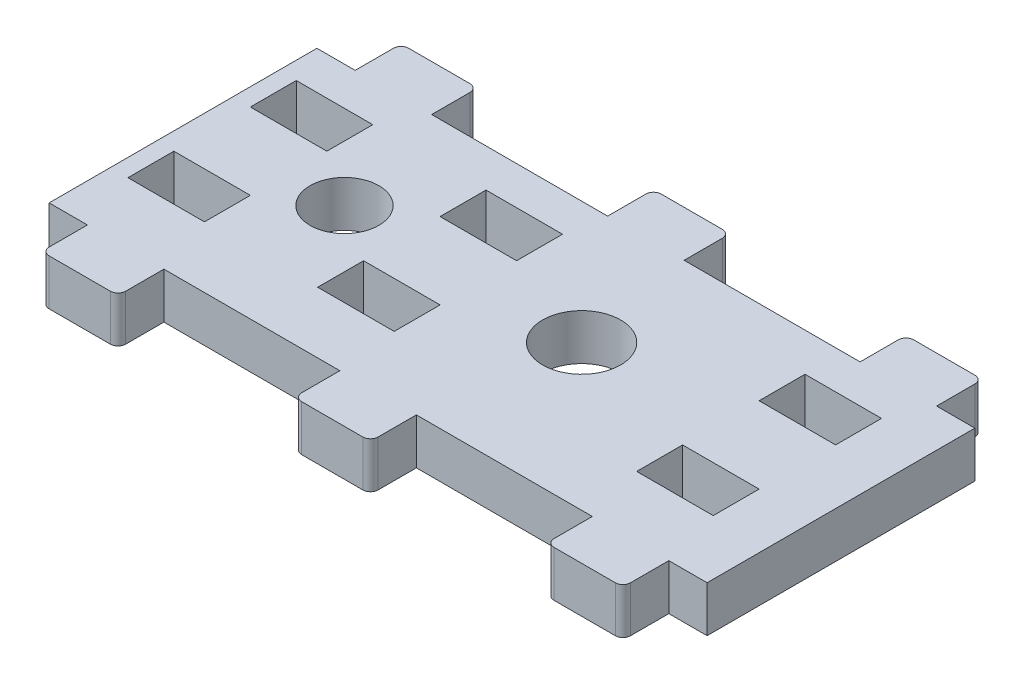
from build123d import *

# Parameters (mm, degrees)
SKETCH1_W               = 86
SKETCH1_H               = 35
BOSS_EXTRUDE1_DEPTH     = 6
SKETCH2_R               = 5.1
SKETCH2_R_2             = 4.5
CUT_EXTRUDE1_DEPTH      = 6
SKETCH234_W             = 10
SKETCH234_H             = 6
BOSS_EXTRUDE234_DEPTH   = 6
FILLET134_R             = 1
SKETCH2341_W            = 10
SKETCH2341_H            = 6
BOSS_EXTRUDE2341_DEPTH  = 6
FILLET1341_R            = 1
SKETCH2342_W            = 10
SKETCH2342_H            = 6
BOSS_EXTRUDE2342_DEPTH  = 6
FILLET1342_R            = 1
FILLET134_OF_MIRROR1_R  = 1
FILLET1341_OF_MIRROR1_R = 1
FILLET1342_OF_MIRROR1_R = 1
SKETCH6_W               = 10
SKETCH6_H               = 6
CUT_EXTRUDE11_DEPTH     = 4
SKETCH61_W              = 10
SKETCH61_H              = 6
CUT_EXTRUDE12_DEPTH     = 4
SKETCH62_W              = 10
SKETCH62_H              = 6
CUT_EXTRUDE13_DEPTH     = 4


with BuildPart() as part:
    # Sketch1 → Boss-Extrude1 (new body)
    with BuildSketch(Plane(origin=(0, 0, 0), x_dir=(1, 0, 0), z_dir=(0, 1, 0))):
        with Locations((43, 17.5)):
            Rectangle(SKETCH1_W, SKETCH1_H)
    extrude(amount=BOSS_EXTRUDE1_DEPTH)

    # Sketch2 → Cut-Extrude1 (cut)
    with BuildSketch(Plane(origin=(0, 6, 0), x_dir=(1, 0, 0), z_dir=(0, 1, 0))):
        with Locations((50.6, 19)):
            Circle(SKETCH2_R)
        with Locations((19.6, 19)):
            Circle(SKETCH2_R_2)
    extrude(amount=-CUT_EXTRUDE1_DEPTH, mode=Mode.SUBTRACT)

    # Sketch234 → Boss-Extrude234 (add)
    with BuildSketch(Plane(origin=(9.232221392, 0, 0), x_dir=(1, 0, 0), z_dir=(0, 0, 1))):
        with Locations((0.767778608, 3)):
            Rectangle(SKETCH234_W, SKETCH234_H)
    boss_extrude234 = extrude(amount=BOSS_EXTRUDE234_DEPTH)

    # Fillet134
    fillet134_edges = [part.edges().sort_by_distance(p)[0] for p in [
        (5, 3, 6),
        (15, 3, 6),
    ]]
    fillet(fillet134_edges, radius=FILLET134_R)

    # Sketch2341 → Boss-Extrude2341 (add)
    with BuildSketch(Plane(origin=(42.232221392, 0, 0), x_dir=(1, 0, 0), z_dir=(0, 0, 1))):
        with Locations((0.767778608, 3)):
            Rectangle(SKETCH2341_W, SKETCH2341_H)
    boss_extrude2341 = extrude(amount=BOSS_EXTRUDE2341_DEPTH)

    # Fillet1341
    fillet1341_edges = [part.edges().sort_by_distance(p)[0] for p in [
        (48, 3, 6),
        (38, 3, 6),
    ]]
    fillet(fillet1341_edges, radius=FILLET1341_R)

    # Sketch2342 → Boss-Extrude2342 (add)
    with BuildSketch(Plane(origin=(75.232221392, 0, 0), x_dir=(1, 0, 0), z_dir=(0, 0, 1))):
        with Locations((0.767778608, 3)):
            Rectangle(SKETCH2342_W, SKETCH2342_H)
    boss_extrude2342 = extrude(amount=BOSS_EXTRUDE2342_DEPTH)

    # Fillet1342
    fillet1342_edges = [part.edges().sort_by_distance(p)[0] for p in [
        (81, 3, 6),
        (71, 3, 6),
    ]]
    fillet(fillet1342_edges, radius=FILLET1342_R)

    # Mirror1: Boss-Extrude234, Boss-Extrude2341, Boss-Extrude2342 across plane
    add(boss_extrude234.mirror(Plane(origin=(0, 0, -17.5), x_dir=(1, 0, 0), z_dir=(0, 0, -1))))
    add(boss_extrude2341.mirror(Plane(origin=(0, 0, -17.5), x_dir=(1, 0, 0), z_dir=(0, 0, -1))))
    add(boss_extrude2342.mirror(Plane(origin=(0, 0, -17.5), x_dir=(1, 0, 0), z_dir=(0, 0, -1))))

    # Fillet134 of Mirror1
    fillet134_of_mirror1_edges = [part.edges().sort_by_distance(p)[0] for p in [
        (5, 3, -41),
        (15, 3, -41),
    ]]
    fillet(fillet134_of_mirror1_edges, radius=FILLET134_OF_MIRROR1_R)

    # Fillet1341 of Mirror1
    fillet1341_of_mirror1_edges = [part.edges().sort_by_distance(p)[0] for p in [
        (48, 3, -41),
        (38, 3, -41),
    ]]
    fillet(fillet1341_of_mirror1_edges, radius=FILLET1341_OF_MIRROR1_R)

    # Fillet1342 of Mirror1
    fillet1342_of_mirror1_edges = [part.edges().sort_by_distance(p)[0] for p in [
        (81, 3, -41),
        (71, 3, -41),
    ]]
    fillet(fillet1342_of_mirror1_edges, radius=FILLET1342_OF_MIRROR1_R)

    # Sketch6 → Cut-Extrude11 (cut, symmetric)
    with BuildSketch(Plane(origin=(73.032221392, 3, -55), x_dir=(1, 0, 0), z_dir=(0, 1, 0))):
        with Locations((0.767778608, -44)):
            Rectangle(SKETCH6_W, SKETCH6_H)
    cut_extrude11 = extrude(amount=CUT_EXTRUDE11_DEPTH, both=True, mode=Mode.SUBTRACT)

    # Sketch61 → Cut-Extrude12 (cut, symmetric)
    with BuildSketch(Plane(origin=(31.332221392, 3, -55), x_dir=(1, 0, 0), z_dir=(0, 1, 0))):
        with Locations((0.767778608, -44)):
            Rectangle(SKETCH61_W, SKETCH61_H)
    cut_extrude12 = extrude(amount=CUT_EXTRUDE12_DEPTH, both=True, mode=Mode.SUBTRACT)

    # Sketch62 → Cut-Extrude13 (cut, symmetric)
    with BuildSketch(Plane(origin=(6.532221392, 3, -55), x_dir=(1, 0, 0), z_dir=(0, 1, 0))):
        with Locations((0.767778608, -44)):
            Rectangle(SKETCH62_W, SKETCH62_H)
    cut_extrude13 = extrude(amount=CUT_EXTRUDE13_DEPTH, both=True, mode=Mode.SUBTRACT)

    # Mirror2: Cut-Extrude11, Cut-Extrude12, Cut-Extrude13 across plane
    add(cut_extrude11.mirror(Plane(origin=(0, 0, -19), x_dir=(1, 0, 0), z_dir=(0, 0, -1))), mode=Mode.SUBTRACT)
    add(cut_extrude12.mirror(Plane(origin=(0, 0, -19), x_dir=(1, 0, 0), z_dir=(0, 0, -1))), mode=Mode.SUBTRACT)
    add(cut_extrude13.mirror(Plane(origin=(0, 0, -19), x_dir=(1, 0, 0), z_dir=(0, 0, -1))), mode=Mode.SUBTRACT)


solid = part.part
